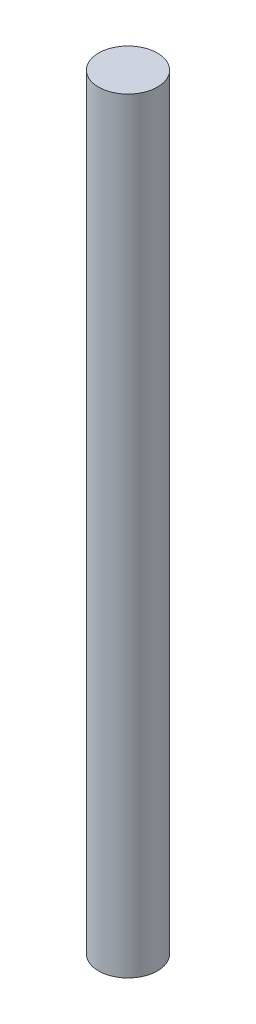
from build123d import *

# Parameters (mm, degrees)
SKETCH1_R           = 6.35
BOSS_EXTRUDE1_DEPTH = 165


with BuildPart() as part:
    # Sketch1 → Boss-Extrude1 (new body)
    with BuildSketch(Plane(origin=(0, 0, 0), x_dir=(1, 0, 0), z_dir=(0, 1, 0))):
        Circle(SKETCH1_R)
    extrude(amount=BOSS_EXTRUDE1_DEPTH)


solid = part.part
